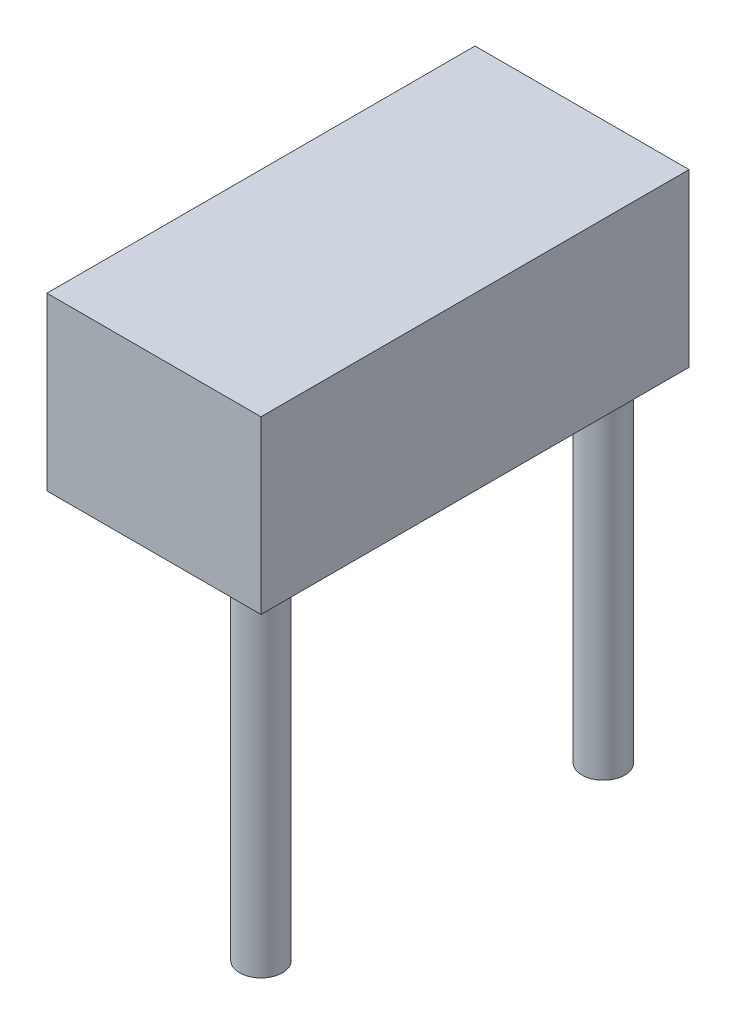
from build123d import *

# Parameters (mm, degrees)
SKETCH1_W           = 15.875
SKETCH1_H           = 31.75
BOSS_EXTRUDE1_DEPTH = 12.7
SKETCH2_R           = 1.5875
BOSS_EXTRUDE2_DEPTH = 25.4


with BuildPart() as part:
    # Sketch1 → Boss-Extrude1 (new body)
    with BuildSketch(Plane(origin=(0, 0, 0), x_dir=(1, 0, 0), z_dir=(0, 1, 0))):
        with Locations((7.9375, 15.875)):
            Rectangle(SKETCH1_W, SKETCH1_H)
    extrude(amount=BOSS_EXTRUDE1_DEPTH)

    # Sketch2 → Boss-Extrude2 (add)
    with BuildSketch(Plane.XZ):
        with Locations((12.7, -3.175)):
            Circle(SKETCH2_R)
        with Locations((12.7, -28.575)):
            Circle(SKETCH2_R)
    extrude(amount=BOSS_EXTRUDE2_DEPTH)


solid = part.part
